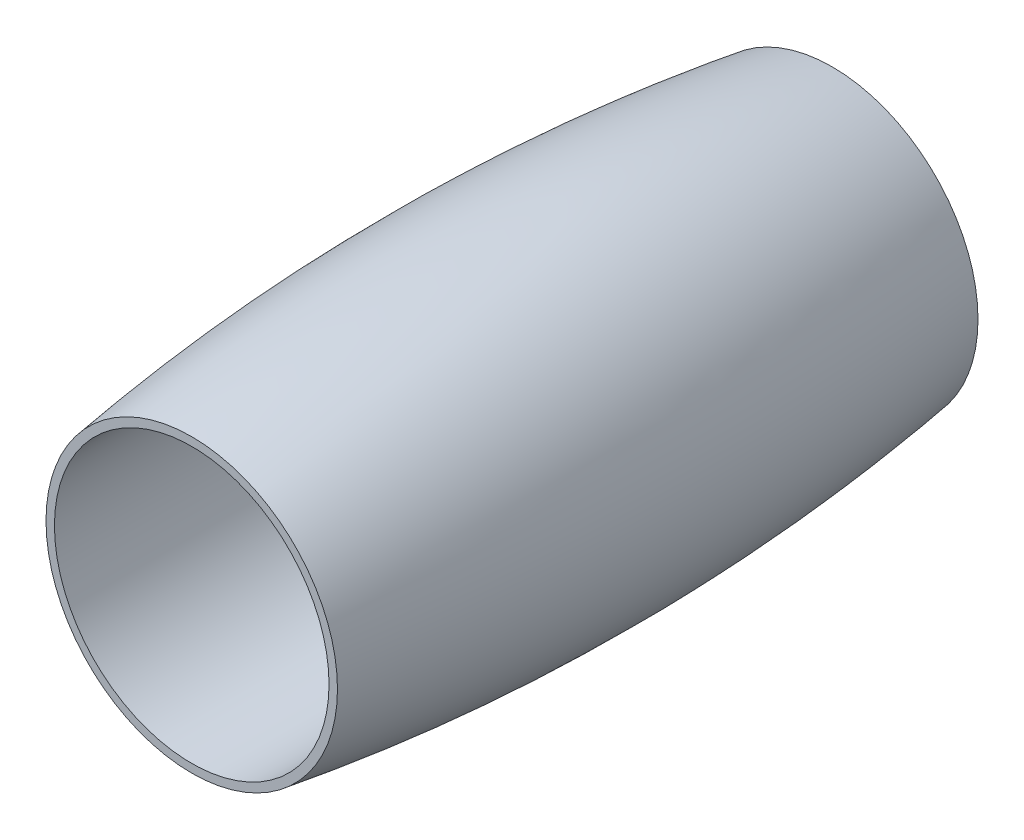
from build123d import *


with BuildPart() as part:
    # Эскиз1 → Повернуть1 (revolve)
    with BuildSketch(Plane(origin=(0, 0, 0), x_dir=(0, 0, -1), z_dir=(1, 0, 0))):
        with BuildLine():
            Line((34.990014613, 15), (-34.990014613, 15))
            Line((-34.990014613, 15), (-34.990014613, 15.921673633))
            add(Edge.make_bspline(
                [(0, 18.5), (-17.684997706, 18.5), (-34.990014613, 15.921673633)],
                knots=[4.71238898, 4.71238898, 4.71238898, 4.920059097, 4.920059097, 4.920059097], degree=2, weights=[1, 0.994613982, 1]))
            add(Edge.make_bspline(
                [(34.990014613, 15.921673633), (17.684997706, 18.5), (0, 18.5)],
                knots=[1.36312621, 1.36312621, 1.36312621, 1.570796327, 1.570796327, 1.570796327], degree=2, weights=[1, 0.994613982, 1]))
            Line((34.990014613, 15.921673633), (34.990014613, 15))
        make_face()
    revolve(axis=Axis((0, 0, 1000), (0, 0, -1)))


solid = part.part
